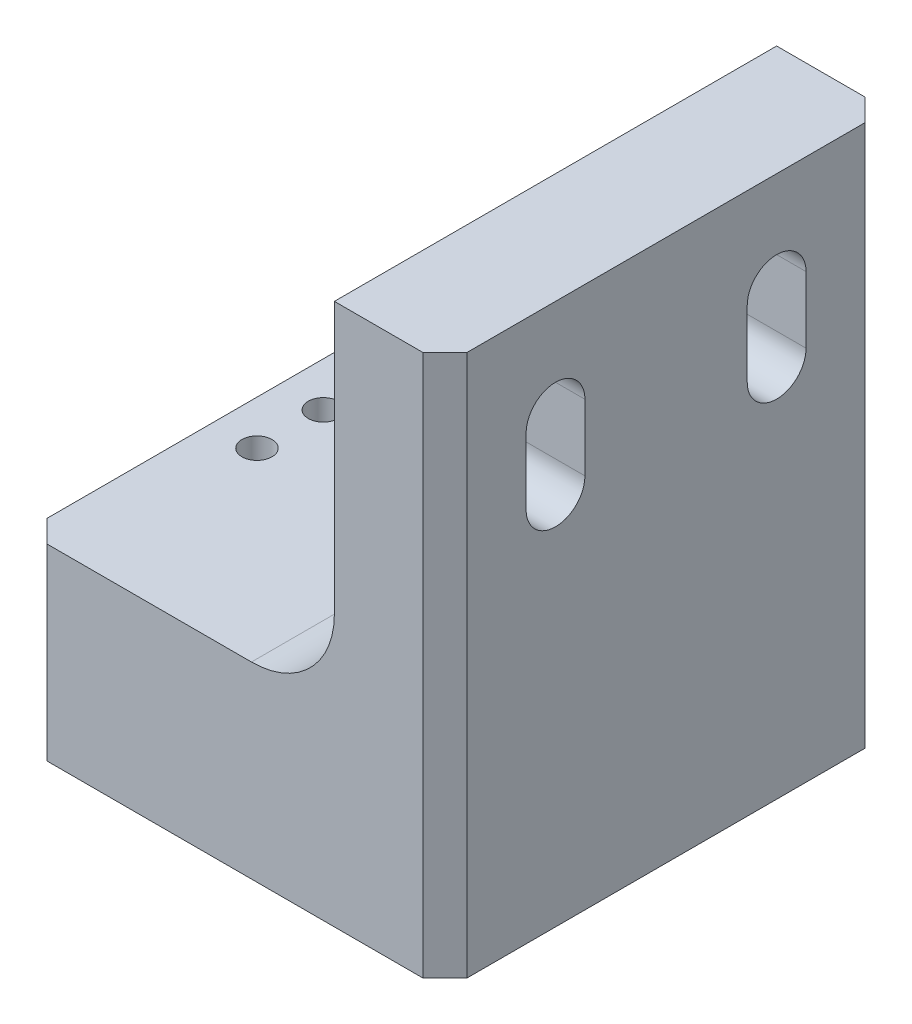
from build123d import *

# Parameters (mm, degrees)
EXTRUDE1_DEPTH        = 25.4
EXTRUDE1_DEPTH_BACK   = 25.4
F_4_CLEARANCE_HOLE1_D = 3.4544
EXTRUDE2_DEPTH        = 49.26
LPATTERN1_COUNT       = 2
LPATTERN1_PITCH       = 25.4
FILLET2_R             = 9.525
CHAMFER1_SIZE         = 2.54


with BuildPart() as part:
    # Sketch1 → Extrude1 (new body, two sides)
    with BuildSketch(Plane.XY) as extrude1_sk:
        Polygon((0, 0), (48.26, 0), (48.26, 62.23), (35.56, 62.23), (35.56, 21.59), (0, 21.59), align=None)
    extrude(amount=EXTRUDE1_DEPTH)
    extrude(extrude1_sk.sketch, amount=-EXTRUDE1_DEPTH_BACK)

    # 4 Clearance Hole1 (through all)
    with Locations(Plane(origin=(0, 21.59, 0), x_dir=(-1, 0, 0), z_dir=(0, 1, 0))):
        with Locations((-5.08, -3.81), (-5.08, 3.81)):
            Hole(F_4_CLEARANCE_HOLE1_D / 2)

    # Sketch4 → Extrude2 (cut, through all)
    with BuildSketch(Plane(origin=(48.26, 0, 0), x_dir=(0, 0, -1), z_dir=(1, 0, 0))):
        with BuildLine():
            Line((16.0782, 50.8), (16.0782, 43.18))
            ThreePointArc((16.0782, 43.18), (12.7, 39.8018), (9.3218, 43.18))
            Line((9.3218, 43.18), (9.3218, 50.8))
            ThreePointArc((9.3218, 50.8), (12.7, 54.1782), (16.0782, 50.8))
        make_face()
    extrude2 = extrude(amount=-EXTRUDE2_DEPTH, mode=Mode.SUBTRACT)

    # LPattern1: Extrude2 ×2
    with Locations(*[(0, 0, i * LPATTERN1_PITCH) for i in range(1, LPATTERN1_COUNT)]):
        add(extrude2, mode=Mode.SUBTRACT)

    # Fillet2
    fillet2_edges = [part.edges().sort_by_distance(p)[0] for p in [
        (35.56, 21.59, 0),
    ]]
    fillet(fillet2_edges, radius=FILLET2_R)

    # Chamfer1
    chamfer1_edges = [part.edges().sort_by_distance(p)[0] for p in [
        (48.26, 31.115, -25.4),
        (0, 10.795, 25.4),
        (48.26, 31.115, 25.4),
        (0, 10.795, -25.4),
    ]]
    chamfer(chamfer1_edges, length=CHAMFER1_SIZE)


solid = part.part
